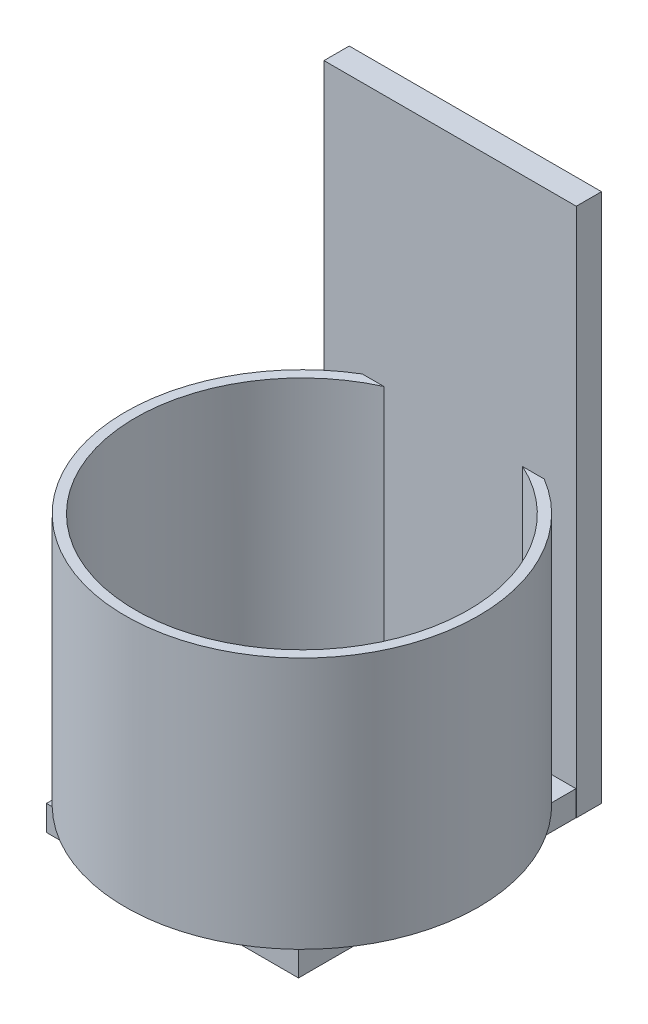
from build123d import *

# Parameters (mm, degrees)
SKETCH1_W           = 63.5
SKETCH1_H           = 127
BOSS_EXTRUDE1_DEPTH = 6.35
SKETCH2_W           = 63.430323736
SKETCH2_H           = 76.2
BOSS_EXTRUDE2_DEPTH = 6.35
SKETCH3_W           = 63.5
SKETCH3_H           = 6.35
BOSS_EXTRUDE3_DEPTH = 6.35
SKETCH4_R           = 44.45
SKETCH4_R_2         = 41.91
BOSS_EXTRUDE4_DEPTH = 63.5


with BuildPart() as part:
    # Sketch1 → Boss-Extrude1 (new body)
    with BuildSketch(Plane.XY):
        with Locations((31.75, -63.5)):
            Rectangle(SKETCH1_W, SKETCH1_H)
    extrude(amount=BOSS_EXTRUDE1_DEPTH)



with BuildPart() as body_2:
    # Sketch2 → Boss-Extrude2 (new body)
    with BuildSketch(Plane.XZ.offset(127)):
        with Locations((31.715161868, 38.1)):
            Rectangle(SKETCH2_W, SKETCH2_H)
    extrude(amount=BOSS_EXTRUDE2_DEPTH)


with BuildPart() as part_1:
    add(part.part)

    add(body_2.part)  # Boss-Extrude3 merges body 2
    # Sketch3 → Boss-Extrude3 (add)
    with BuildSketch(Plane.XZ.offset(127)):
        with Locations((31.75, 3.175)):
            Rectangle(SKETCH3_W, SKETCH3_H)
    extrude(amount=BOSS_EXTRUDE3_DEPTH)

    # Sketch4 → Boss-Extrude4 (add)
    with BuildSketch(Plane(origin=(0, -63.5, 0), x_dir=(1, 0, 0), z_dir=(0, 1, 0))):
        with Locations((32.537747745, -44.45)):
            Circle(SKETCH4_R)
        with Locations((32.537747745, -44.45)):
            Circle(SKETCH4_R_2, mode=Mode.SUBTRACT)
    extrude(amount=-BOSS_EXTRUDE4_DEPTH)


solid = part_1.part
